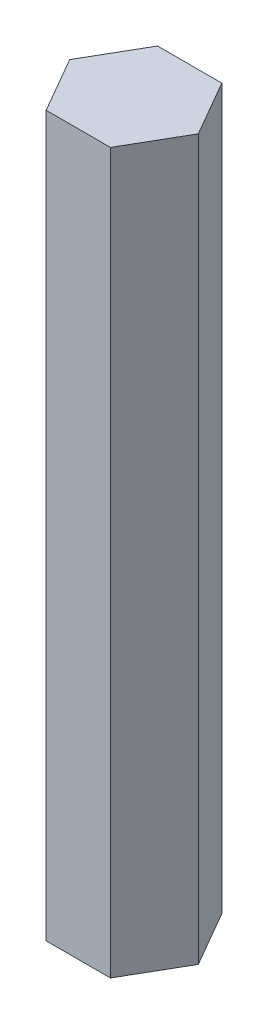
from build123d import *

# Parameters (mm, degrees)
BOSS_EXTRUDE1_DEPTH = 89.5


with BuildPart() as part:
    # Sketch1 → Boss-Extrude1 (new body)
    with BuildSketch(Plane(origin=(0, 0, 0), x_dir=(1, 0, 0), z_dir=(0, 1, 0))):
        Polygon((7.977059052, 1.579344013), (3.977059052, 8.507547244), (-4.022940948, 8.507547244), (-8.022940948, 1.579344013), (-4.022940948, -5.348859217), (3.977059052, -5.348859217), align=None)
    extrude(amount=BOSS_EXTRUDE1_DEPTH)


solid = part.part
